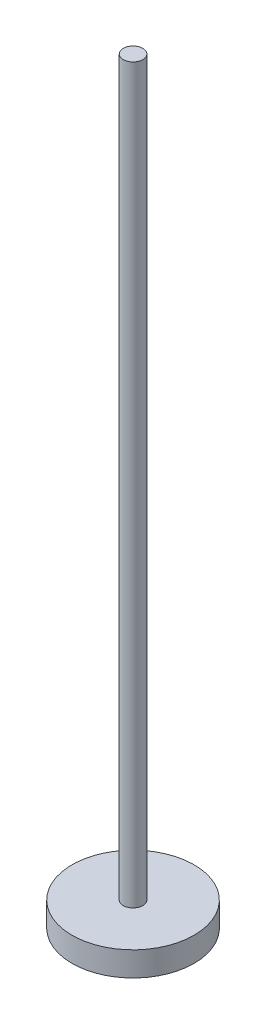
from build123d import *


with BuildPart() as part:
    # Sketch1 → Revolve1 (revolve)
    with BuildSketch(Plane.XY):
        Polygon((4, 300), (4, 0), (25, 0), (25, -10), (0, -10), (0, 300), align=None)
    revolve(axis=Axis((0, -1655.000540862, 0), (0, 1, 0)))


solid = part.part
